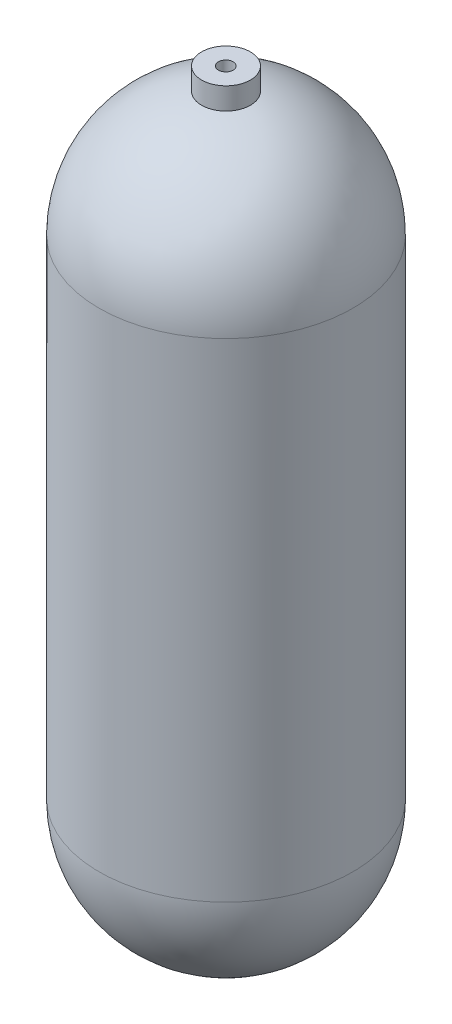
from build123d import *

# Parameters (mm, degrees)
BOSS_EXTRUDE1_REACH              = 498.52
BOSS_EXTRUDE1_END_RADIUS         = 82.55
SKETCH2_R                        = 15.875
BOSS_EXTRUDE1_DIRECTION_2_DEPTH  = 12.7
F_3_8_0_375_DIAMETER_HOLE1_D     = 9.525
F_3_8_0_375_DIAMETER_HOLE1_DEPTH = 25.4
F_3_8_0_375_DIAMETER_HOLE1_TIP   = 2.861598698


with BuildPart() as part:
    # Sketch1 → Revolve1 (revolve)
    with BuildSketch(Plane.XY):
        with BuildLine():
            Line((82.55, 400.05), (82.55, 82.55))
            ThreePointArc((82.55, 82.55), (58.371664787, 24.178335213), (0, 0))
            Line((0, 0), (0, 3.175))
            ThreePointArc((0, 3.175), (56.126600757, 26.423399243), (79.375, 82.55))
            Line((79.375, 82.55), (79.375, 400.05))
            ThreePointArc((79.375, 400.05), (56.126600757, 456.176600757), (0, 479.425))
            Line((0, 479.425), (0, 482.6))
            ThreePointArc((0, 482.6), (58.371664787, 458.421664787), (82.55, 400.05))
        make_face()
    revolve(axis=Axis((0, 482.6, 0), (0, 1, 0)))

    # Boss-Extrude1: up to this sphere (the profile starts outside it)
    boss_extrude1_end = Location((0, 400.05, 0)) * Sphere(BOSS_EXTRUDE1_END_RADIUS, mode=Mode.PRIVATE)
    # Sketch2 → Boss-Extrude1 (add, up to the surface)
    with BuildSketch(Plane(origin=(0, 482.6, 0), x_dir=(1, 0, 0), z_dir=(0, 1, 0)), mode=Mode.PRIVATE) as boss_extrude1_sk1:
        with Locations(Location((0, 0, 0), (0, 0, 270))):
            Circle(SKETCH2_R)
    boss_extrude1_tool1 = extrude(boss_extrude1_sk1.sketch, amount=-BOSS_EXTRUDE1_REACH, mode=Mode.PRIVATE) - boss_extrude1_end
    add(boss_extrude1_tool1.solids().sort_by_distance((0, 482.6, 0))[0])

    # Sketch2 → Boss-Extrude1 direction 2 (add)
    with BuildSketch(Plane(origin=(0, 482.6, 0), x_dir=(1, 0, 0), z_dir=(0, 1, 0))):
        with Locations(Location((0, 0, 0), (0, 0, 270))):
            Circle(SKETCH2_R)
    extrude(amount=BOSS_EXTRUDE1_DIRECTION_2_DEPTH)

    # 3/8 (0.375) Diameter Hole1
    with Locations(Plane(origin=(-0.053238661, 495.3, 0.09377676), x_dir=(0, 0, 1), z_dir=(0, 1, 0))):
        with Locations((0, 0)):
            Hole(F_3_8_0_375_DIAMETER_HOLE1_D / 2, depth=F_3_8_0_375_DIAMETER_HOLE1_DEPTH)
            with Locations((0, 0, -(F_3_8_0_375_DIAMETER_HOLE1_DEPTH + F_3_8_0_375_DIAMETER_HOLE1_TIP / 2))):  # 118° drill point
                Cone(0, F_3_8_0_375_DIAMETER_HOLE1_D / 2, F_3_8_0_375_DIAMETER_HOLE1_TIP, mode=Mode.SUBTRACT)


solid = part.part
